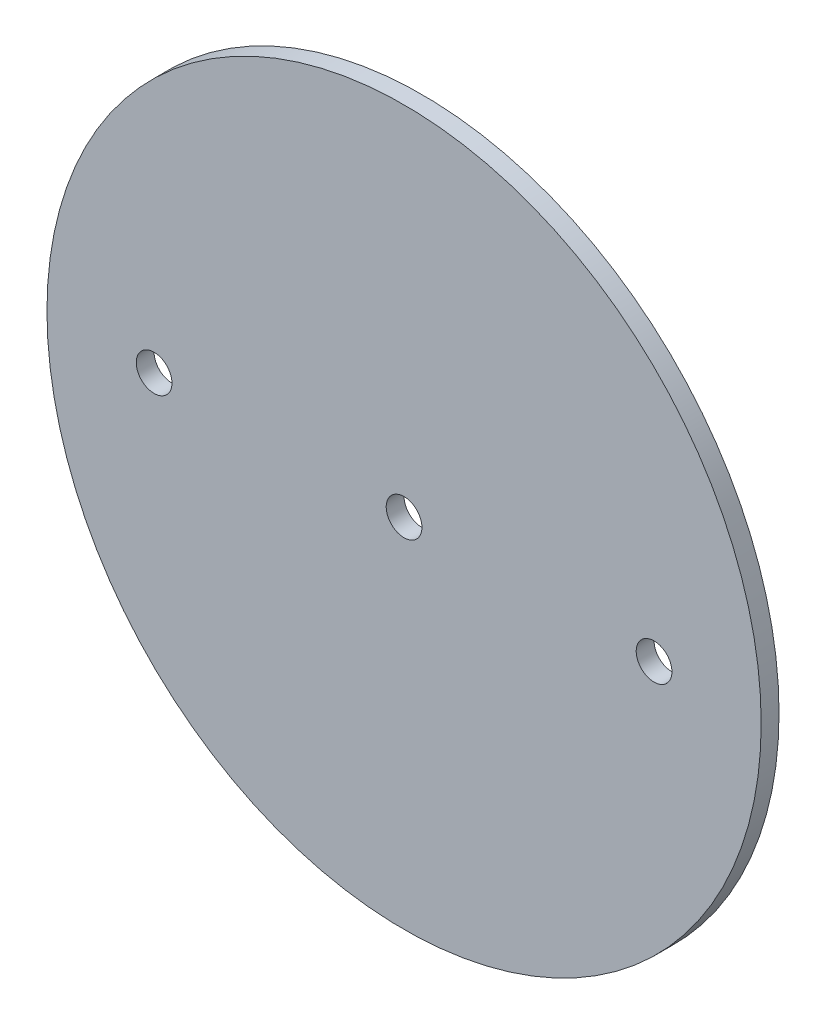
from build123d import *

# Parameters (mm, degrees)
SKETCH1_R                   = 63.5
BOSS_EXTRUDE1_DEPTH         = 1.5875
F_1_4_0_25_DIAMETER_HOLE1_D = 6.35


with BuildPart() as part:
    # Sketch1 → Boss-Extrude1 (new body, symmetric)
    with BuildSketch(Plane.XY):
        Circle(SKETCH1_R)
    extrude(amount=BOSS_EXTRUDE1_DEPTH, both=True)

    # 1/4 (0.25) Diameter Hole1 (through all)
    with Locations(Plane.XY.offset(1.5875)):
        with Locations((-44.45, 0), (0, 0), (44.45, 0)):
            Hole(F_1_4_0_25_DIAMETER_HOLE1_D / 2)


solid = part.part
